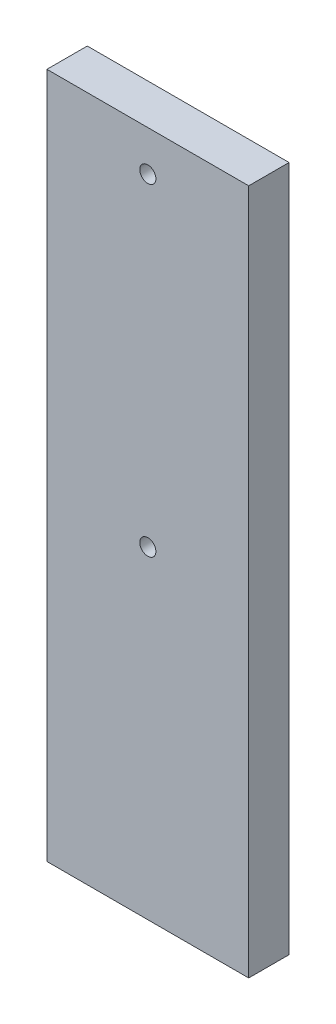
from build123d import *

# Parameters (mm, degrees)
SKETCH_1_W      = 50
SKETCH_1_H      = 170
SKETCH_1_R      = 2
EXTRUDE_1_DEPTH = 10


with BuildPart() as part:
    # 草图1 → 凸台-拉伸1 (new body)
    with BuildSketch(Plane.XY):
        with Locations((-4.772681171, -44.472429595)):
            Rectangle(SKETCH_1_W, SKETCH_1_H)
        with Locations((-4.772681171, 30.527570405)):
            Circle(SKETCH_1_R, mode=Mode.SUBTRACT)
        with Locations((-4.772681171, -49.472429595)):
            Circle(SKETCH_1_R, mode=Mode.SUBTRACT)
    extrude(amount=EXTRUDE_1_DEPTH)


solid = part.part
